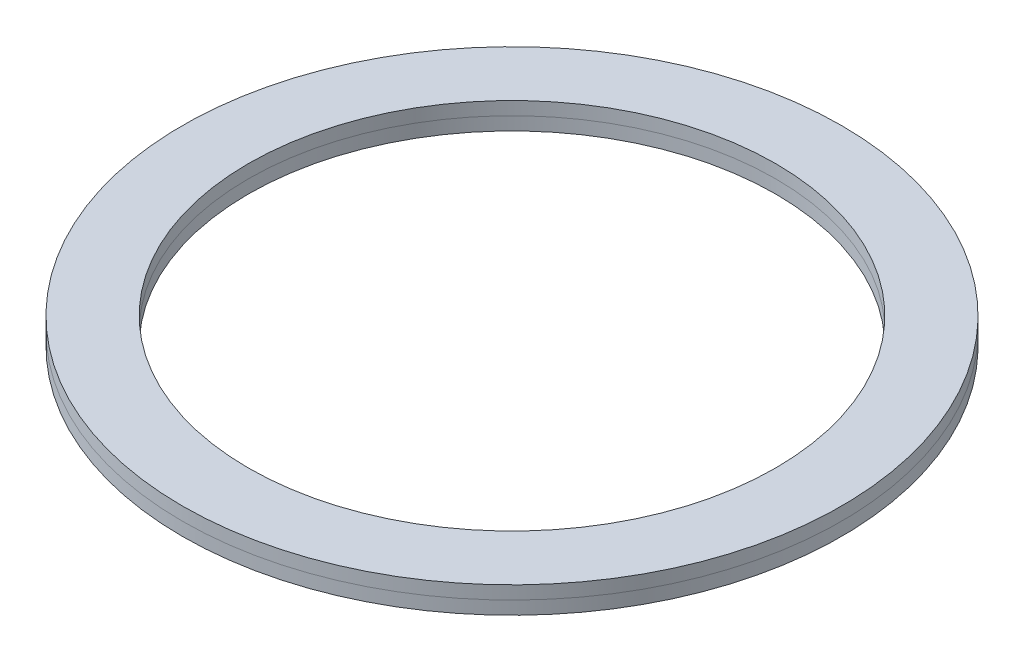
from build123d import *

# Parameters (mm, degrees)
SKETCH1_W = 5
SKETCH1_H = 2


with BuildPart() as part:
    # Sketch1 → Revolve1 (revolve)
    with BuildSketch(Plane.XY):
        with Locations((-22.5, 1)):
            Rectangle(SKETCH1_W, SKETCH1_H)
    revolve(axis=Axis((0, 0, 0), (0, 1, 0)))


with BuildPart() as body_2:
    # Split1: the piece on the far side of the plane
    add(part.part)
    split(bisect_by=Plane.ZX.offset(1), keep=Keep.BOTTOM)


with BuildPart() as part_1:
    add(part.part)

    # Split1
    split(bisect_by=Plane.ZX.offset(1), keep=Keep.TOP)


solid = Compound([body_2.part, part_1.part])
